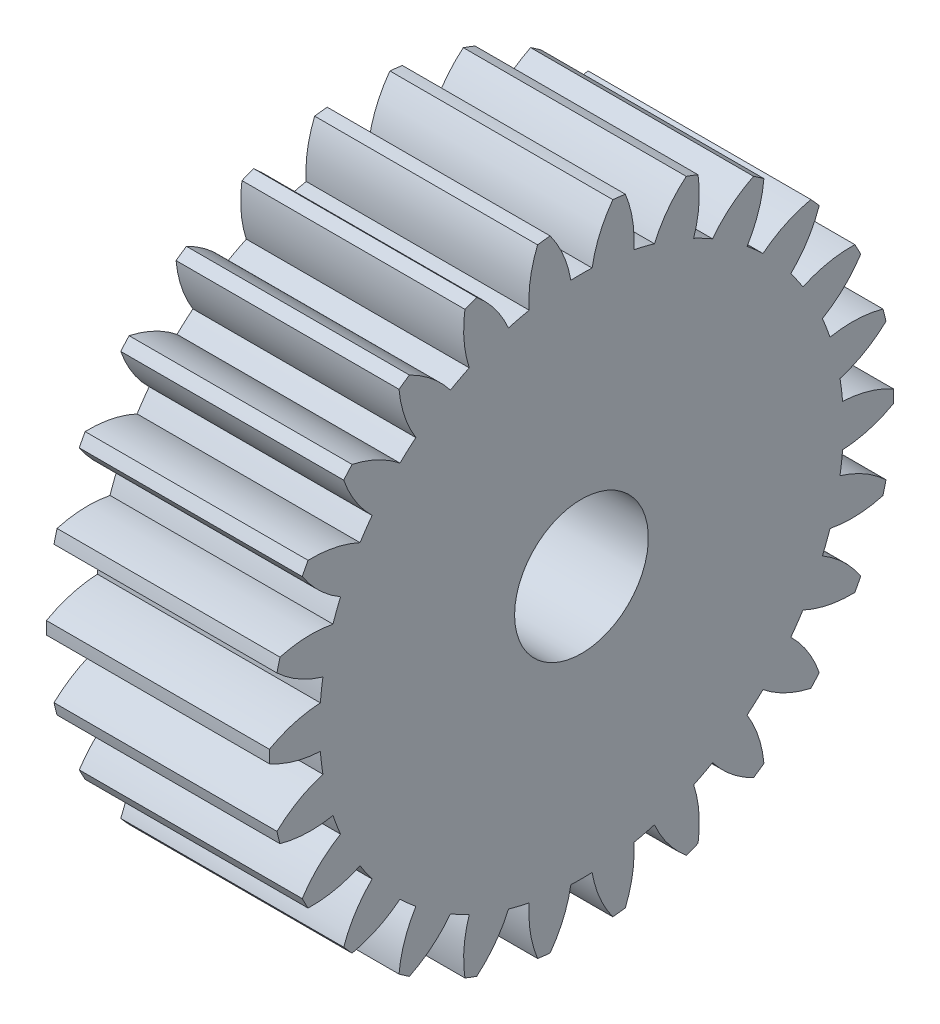
from build123d import *

# Parameters (mm, degrees)
BASPROSKE_W     = 10
BASPROSKE_H     = 14
TOOTHCUT_DEPTH  = 23.181073013
TEETHCUTS_COUNT = 26
TEETHCUTS_ANGLE = 346.153846154
BORSKE_R        = 3
BORE_DEPTH      = 50.0000508


with BuildPart() as part:
    # BasProSke → Base-Revolve (revolve)
    with BuildSketch(Plane(origin=(0, 0, 0), x_dir=(1, 0, 0), z_dir=(0, 1, 0)), mode=Mode.PRIVATE) as base_revolve_sk:
        with Locations((5, 7)):
            Rectangle(BASPROSKE_W, BASPROSKE_H)
    revolve(base_revolve_sk.sketch.rotate(Axis((-10, 0, 0), (1, 0, 0)), 180), axis=Axis((-10, 0, 0), (1, 0, 0)))

    # TooCutSke → ToothCut (cut, through all)
    with BuildSketch(Plane(origin=(0, 0, 0), x_dir=(0, 0, -1), z_dir=(1, 0, 0))):
        with BuildLine():
            ThreePointArc((0.476965065, 11.739314517), (0, 11.749), (-0.476965065, 11.739314517))
            ThreePointArc((-0.476965065, 11.739314517), (-0.82065865, 12.901686978), (-1.424117301, 13.952911348))
            ThreePointArc((-1.424117301, 13.952911348), (0, 14.0254), (1.424117301, 13.952911348))
            ThreePointArc((1.424117301, 13.952911348), (0.82065865, 12.901686978), (0.476965065, 11.739314517))
        make_face()
    toothcut = extrude(amount=TOOTHCUT_DEPTH, mode=Mode.SUBTRACT)

    # TeethCuts: ToothCut ×26 about axis
    teethcuts_axis = Axis((-10, 0, 0), (1, 0, 0))
    for i in range(1, TEETHCUTS_COUNT):
        add(toothcut.rotate(teethcuts_axis, i * TEETHCUTS_ANGLE / (TEETHCUTS_COUNT - 1)), mode=Mode.SUBTRACT)

    # BorSke → Bore (cut, symmetric)
    with BuildSketch(Plane(origin=(0, 0, 0), x_dir=(0, 0, -1), z_dir=(1, 0, 0))):
        with Locations(Location((0, 0, 0), (0, 0, 180))):
            Circle(BORSKE_R)
    extrude(amount=BORE_DEPTH, both=True, mode=Mode.SUBTRACT)


solid = part.part
